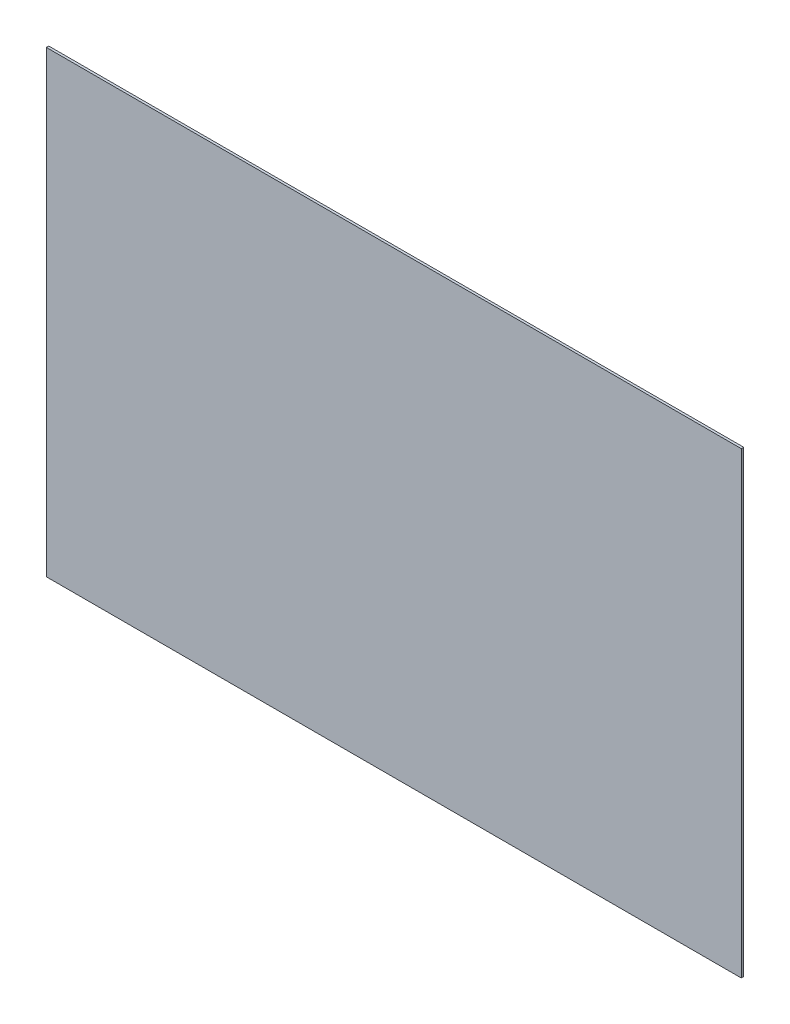
from build123d import *

# Parameters (mm, degrees)
SKETCH1_W           = 914.4
SKETCH1_H           = 603.25
BOSS_EXTRUDE1_DEPTH = 3.175


with BuildPart() as part:
    # Sketch1 → Boss-Extrude1 (new body)
    with BuildSketch(Plane.XY):
        Rectangle(SKETCH1_W, SKETCH1_H)
    extrude(amount=BOSS_EXTRUDE1_DEPTH)


solid = part.part
